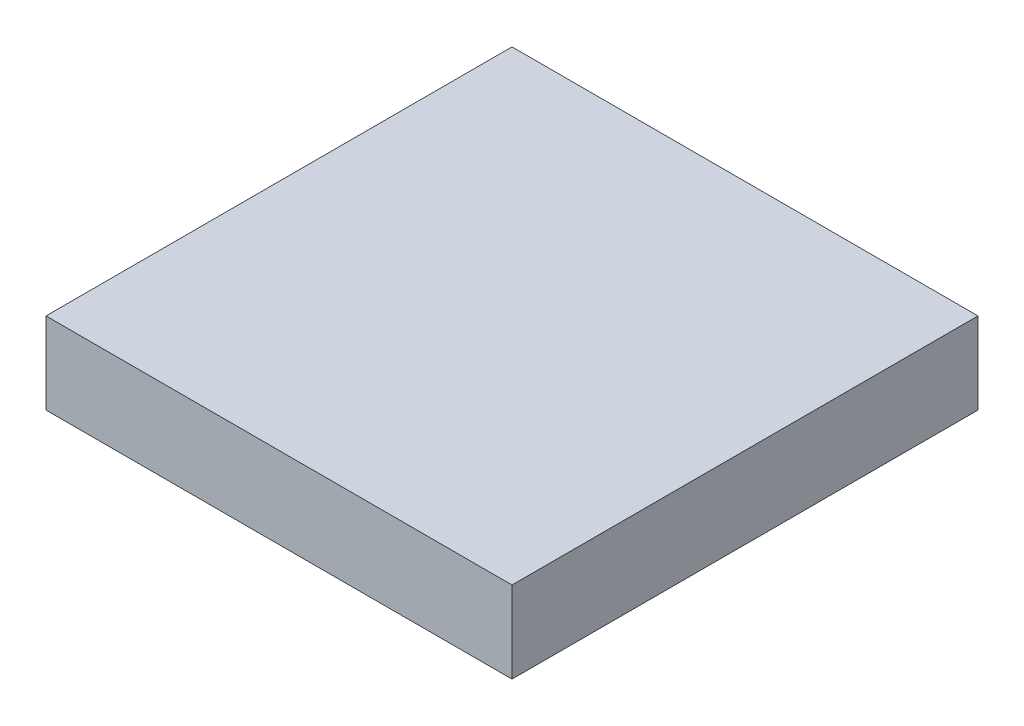
from build123d import *

# Parameters (mm, degrees)
SKETCH1_W           = 57.15
SKETCH1_H           = 57.15
BOSS_EXTRUDE1_DEPTH = 10
SKETCH2_W           = 57.15
SKETCH2_H           = 57.15
BOSS_EXTRUDE2_DEPTH = 10


with BuildPart() as part:
    # Sketch1 → Boss-Extrude1 (new body)
    with BuildSketch(Plane(origin=(0, 0, 0), x_dir=(1, 0, 0), z_dir=(0, 1, 0))):
        Rectangle(SKETCH1_W, SKETCH1_H)
    extrude(amount=BOSS_EXTRUDE1_DEPTH)


with BuildPart() as body_2:
    # Sketch2 → Boss-Extrude2 (new body)
    with BuildSketch(Plane(origin=(0, 0, 0), x_dir=(1, 0, 0), z_dir=(0, 1, 0))):
        Rectangle(SKETCH2_W, SKETCH2_H)
    extrude(amount=BOSS_EXTRUDE2_DEPTH)


solid = Compound([part.part, body_2.part])
